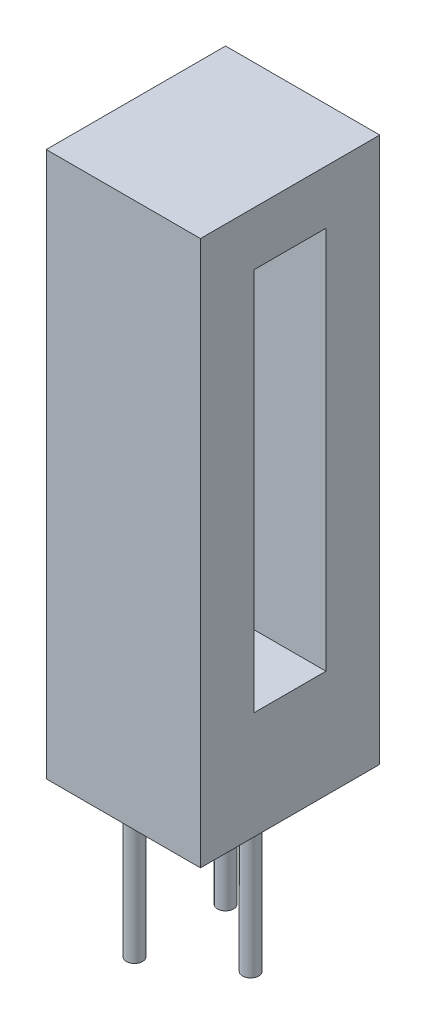
from build123d import *

# Parameters (mm, degrees)
SKETCH1_W           = 4.3
SKETCH1_H           = 15.2
BOSS_EXTRUDE1_DEPTH = 5
SKETCH2_W           = 2
SKETCH2_H           = 10.7
CUT_EXTRUDE1_DEPTH  = 2
SKETCH3_R           = 0.225
BOSS_EXTRUDE2_DEPTH = 4.3


with BuildPart() as part:
    # Sketch1 → Boss-Extrude1 (new body)
    with BuildSketch(Plane.XY):
        with Locations((2.15, 7.6)):
            Rectangle(SKETCH1_W, SKETCH1_H)
    extrude(amount=-BOSS_EXTRUDE1_DEPTH)

    # Sketch2 → Cut-Extrude1 (cut)
    with BuildSketch(Plane(origin=(4.3, 0, 0), x_dir=(0, 0, -1), z_dir=(1, 0, 0))):
        with Locations((2.5, 8.35)):
            Rectangle(SKETCH2_W, SKETCH2_H)
    extrude(amount=-CUT_EXTRUDE1_DEPTH, mode=Mode.SUBTRACT)

    # Sketch3 → Boss-Extrude2 (add)
    with BuildSketch(Plane.XZ):
        with Locations((1.23, -1.23)):
            Circle(SKETCH3_R)
        with Locations((1.23, -3.77)):
            Circle(SKETCH3_R)
        with Locations((3.2, -2.5)):
            Circle(SKETCH3_R)
    extrude(amount=BOSS_EXTRUDE2_DEPTH)


solid = part.part
